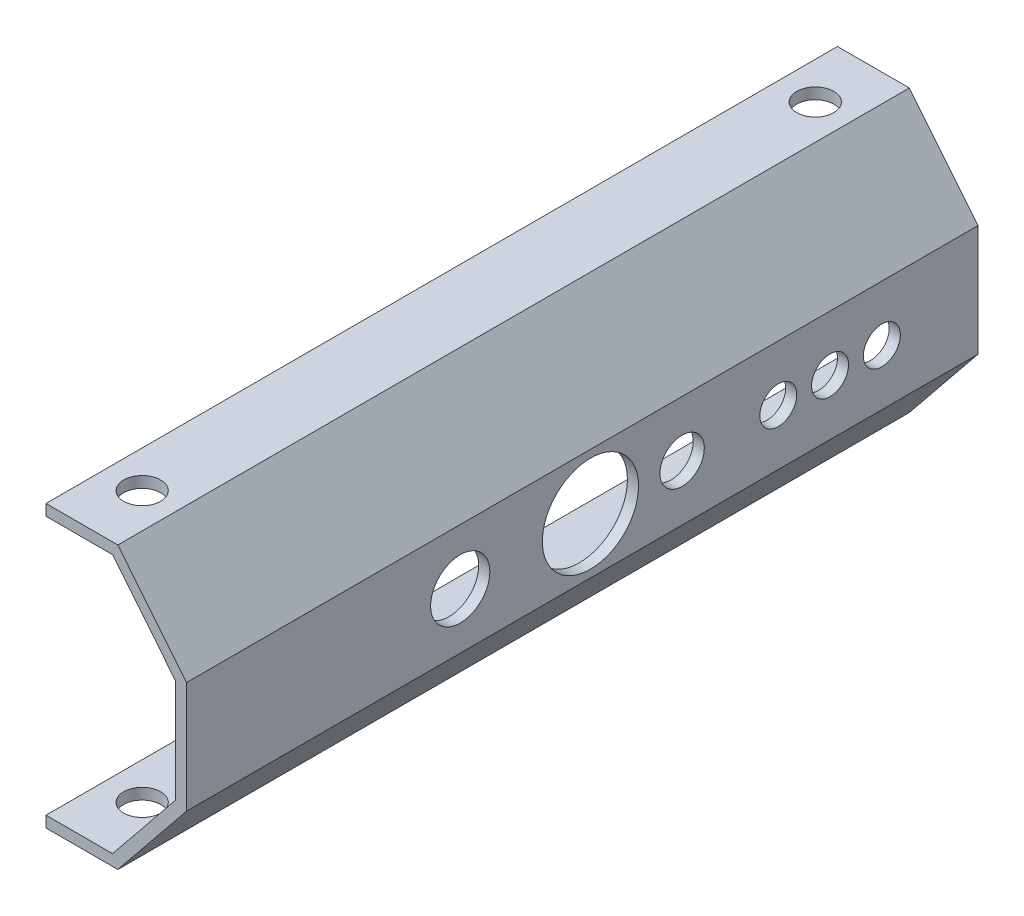
from build123d import *

# Parameters (mm, degrees)
SALIENTE_EXTRUIR1_DEPTH = 107
CORTAR_EXTRUIR1_REACH   = 40
CROQUIS3_R              = 2.5
CORTAR_EXTRUIR2_REACH   = 40
CROQUIS4_R              = 2.5
CORTAR_EXTRUIR3_REACH   = 21
CROQUIS5_R              = 3
CROQUIS5_R_2            = 4
CORTAR_EXTRUIR4_REACH   = 21
CROQUIS6_R              = 6.5
CORTAR_EXTRUIR5_REACH   = 21
CROQUIS7_R              = 2.5


with BuildPart() as part:
    # Croquis1 → Saliente-Extruir1 (new body)
    with BuildSketch(Plane.XY):
        Polygon((0, 0), (9, 0), (17.5, 10.5), (17.5, 24.5), (9, 35), (0, 35), (0, 36.5), (9.715608012, 36.5), (19, 25.031045192), (19, 9.968954808), (9.715608012, -1.5), (0, -1.5), align=None)
    extrude(amount=SALIENTE_EXTRUIR1_DEPTH)

    # Croquis3 → Cortar-Extruir1 (cut, up to next)
    with BuildSketch(Plane(origin=(0, 36.5, 0), x_dir=(1, 0, 0), z_dir=(0, 1, 0)), mode=Mode.PRIVATE) as cortar_extruir1_sk1:
        with Locations((5, -8)):
            Circle(CROQUIS3_R)
    cortar_extruir1_tool1 = extrude(cortar_extruir1_sk1.sketch, amount=-CORTAR_EXTRUIR1_REACH, mode=Mode.PRIVATE) & part.part
    add(cortar_extruir1_tool1.solids().sort_by_distance((5, 36.5, 8))[0], mode=Mode.SUBTRACT)
    # Croquis3 → Cortar-Extruir1 (cut, up to next)
    with BuildSketch(Plane(origin=(0, 36.5, 0), x_dir=(1, 0, 0), z_dir=(0, 1, 0)), mode=Mode.PRIVATE) as cortar_extruir1_sk2:
        with Locations((5, -99)):
            Circle(CROQUIS3_R)
    cortar_extruir1_tool2 = extrude(cortar_extruir1_sk2.sketch, amount=-CORTAR_EXTRUIR1_REACH, mode=Mode.PRIVATE) & part.part
    add(cortar_extruir1_tool2.solids().sort_by_distance((5, 36.5, 99))[0], mode=Mode.SUBTRACT)

    # Croquis4 → Cortar-Extruir2 (cut, up to next)
    with BuildSketch(Plane.XZ.offset(1.5), mode=Mode.PRIVATE) as cortar_extruir2_sk1:
        with Locations((5, 8)):
            Circle(CROQUIS4_R)
    cortar_extruir2_tool1 = extrude(cortar_extruir2_sk1.sketch, amount=-CORTAR_EXTRUIR2_REACH, mode=Mode.PRIVATE) & part.part
    add(cortar_extruir2_tool1.solids().sort_by_distance((5, -1.5, 8))[0], mode=Mode.SUBTRACT)
    # Croquis4 → Cortar-Extruir2 (cut, up to next)
    with BuildSketch(Plane.XZ.offset(1.5), mode=Mode.PRIVATE) as cortar_extruir2_sk2:
        with Locations((5, 99)):
            Circle(CROQUIS4_R)
    cortar_extruir2_tool2 = extrude(cortar_extruir2_sk2.sketch, amount=-CORTAR_EXTRUIR2_REACH, mode=Mode.PRIVATE) & part.part
    add(cortar_extruir2_tool2.solids().sort_by_distance((5, -1.5, 99))[0], mode=Mode.SUBTRACT)

    # Croquis5 → Cortar-Extruir3 (cut, up to next)
    with BuildSketch(Plane(origin=(19, 0, 0), x_dir=(0, 0, -1), z_dir=(1, 0, 0)), mode=Mode.PRIVATE) as cortar_extruir3_sk1:
        with Locations((-40, 17.5)):
            Circle(CROQUIS5_R)
    cortar_extruir3_tool1 = extrude(cortar_extruir3_sk1.sketch, amount=-CORTAR_EXTRUIR3_REACH, mode=Mode.PRIVATE) & part.part
    add(cortar_extruir3_tool1.solids().sort_by_distance((19, 17.5, 40))[0], mode=Mode.SUBTRACT)
    # Croquis5 → Cortar-Extruir3 (cut, up to next)
    with BuildSketch(Plane(origin=(19, 0, 0), x_dir=(0, 0, -1), z_dir=(1, 0, 0)), mode=Mode.PRIVATE) as cortar_extruir3_sk2:
        with Locations((-70, 17.5)):
            Circle(CROQUIS5_R_2)
    cortar_extruir3_tool2 = extrude(cortar_extruir3_sk2.sketch, amount=-CORTAR_EXTRUIR3_REACH, mode=Mode.PRIVATE) & part.part
    add(cortar_extruir3_tool2.solids().sort_by_distance((19, 17.5, 70))[0], mode=Mode.SUBTRACT)

    # Croquis6 → Cortar-Extruir4 (cut, up to next)
    with BuildSketch(Plane(origin=(19, 0, 0), x_dir=(0, 0, -1), z_dir=(1, 0, 0)), mode=Mode.PRIVATE) as cortar_extruir4_sk1:
        with Locations((-52.395650843, 17.501045192)):
            Circle(CROQUIS6_R)
    cortar_extruir4_tool1 = extrude(cortar_extruir4_sk1.sketch, amount=-CORTAR_EXTRUIR4_REACH, mode=Mode.PRIVATE) & part.part
    add(cortar_extruir4_tool1.solids().sort_by_distance((19, 17.501045, 52.395651))[0], mode=Mode.SUBTRACT)

    # Croquis7 → Cortar-Extruir5 (cut, up to next)
    with BuildSketch(Plane(origin=(19, 0, 0), x_dir=(0, 0, -1), z_dir=(1, 0, 0)), mode=Mode.PRIVATE) as cortar_extruir5_sk1:
        with Locations((-27, 17.503954808)):
            Circle(CROQUIS7_R)
    cortar_extruir5_tool1 = extrude(cortar_extruir5_sk1.sketch, amount=-CORTAR_EXTRUIR5_REACH, mode=Mode.PRIVATE) & part.part
    add(cortar_extruir5_tool1.solids().sort_by_distance((19, 17.503955, 27))[0], mode=Mode.SUBTRACT)
    # Croquis7 → Cortar-Extruir5 (cut, up to next)
    with BuildSketch(Plane(origin=(19, 0, 0), x_dir=(0, 0, -1), z_dir=(1, 0, 0)), mode=Mode.PRIVATE) as cortar_extruir5_sk2:
        with Locations((-20, 17.503954808)):
            Circle(CROQUIS7_R)
    cortar_extruir5_tool2 = extrude(cortar_extruir5_sk2.sketch, amount=-CORTAR_EXTRUIR5_REACH, mode=Mode.PRIVATE) & part.part
    add(cortar_extruir5_tool2.solids().sort_by_distance((19, 17.503955, 20))[0], mode=Mode.SUBTRACT)
    # Croquis7 → Cortar-Extruir5 (cut, up to next)
    with BuildSketch(Plane(origin=(19, 0, 0), x_dir=(0, 0, -1), z_dir=(1, 0, 0)), mode=Mode.PRIVATE) as cortar_extruir5_sk3:
        with Locations((-13, 17.503954808)):
            Circle(CROQUIS7_R)
    cortar_extruir5_tool3 = extrude(cortar_extruir5_sk3.sketch, amount=-CORTAR_EXTRUIR5_REACH, mode=Mode.PRIVATE) & part.part
    add(cortar_extruir5_tool3.solids().sort_by_distance((19, 17.503955, 13))[0], mode=Mode.SUBTRACT)


solid = part.part
